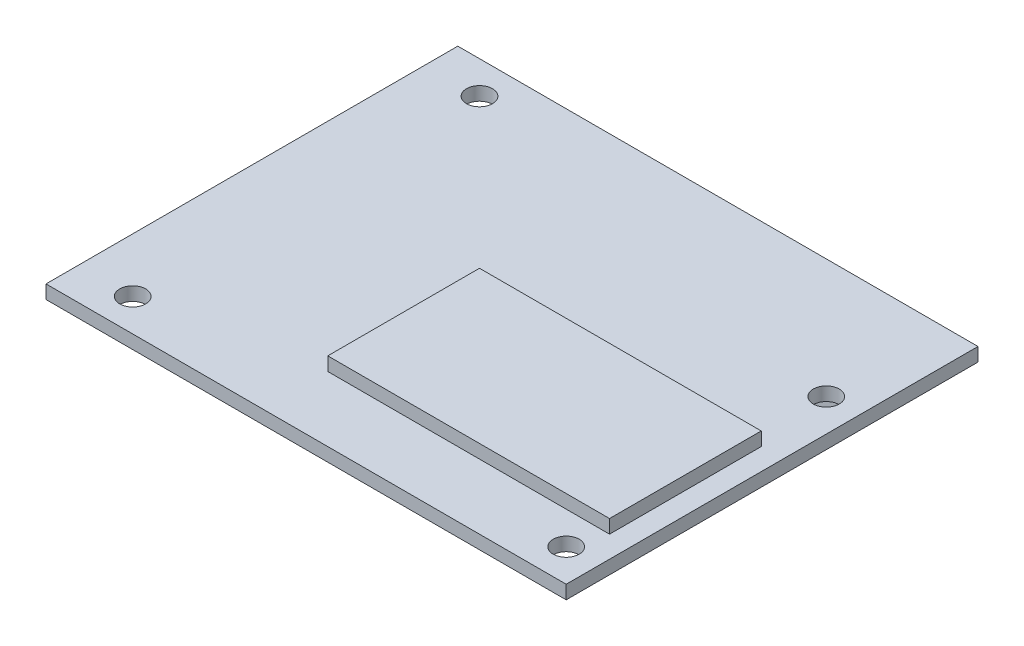
from build123d import *

# Parameters (mm, degrees)
SKETCH1_W           = 60.96
SKETCH1_H           = 48.26
BOSS_EXTRUDE1_DEPTH = 1.5875
SKETCH2_W           = 33.02
SKETCH2_H           = 17.78
BOSS_EXTRUDE2_DEPTH = 1.5875
SKETCH3_R           = 1.524
CUT_EXTRUDE1_DEPTH  = 2.5875
SKETCH4_W           = 12.7
SKETCH4_H           = 2.54
BOSS_EXTRUDE3_DEPTH = 10.16


with BuildPart() as part:
    # Sketch1 → Boss-Extrude1 (new body)
    with BuildSketch(Plane(origin=(0, 0, 0), x_dir=(1, 0, 0), z_dir=(0, 1, 0))):
        with Locations((1.00761446, -5.459482072)):
            Rectangle(SKETCH1_W, SKETCH1_H)
    extrude(amount=BOSS_EXTRUDE1_DEPTH)

    # Sketch2 → Boss-Extrude2 (add)
    with BuildSketch(Plane(origin=(0, 1.5875, 0), x_dir=(1, 0, 0), z_dir=(0, 1, 0))):
        with Locations((12.43761446, -13.079482072)):
            Rectangle(SKETCH2_W, SKETCH2_H)
    extrude(amount=BOSS_EXTRUDE2_DEPTH)

    # Sketch3 → Cut-Extrude1 (cut, through all)
    with BuildSketch(Plane(origin=(0, 1.5875, 0), x_dir=(1, 0, 0), z_dir=(0, 1, 0))):
        with Locations((-23.12238554, 14.860517928)):
            Circle(SKETCH3_R)
        with Locations((27.67761446, 4.700517928)):
            Circle(SKETCH3_R)
        with Locations((-23.12238554, -25.779482072)):
            Circle(SKETCH3_R)
        with Locations((27.67761446, -25.779482072)):
            Circle(SKETCH3_R)
    extrude(amount=-CUT_EXTRUDE1_DEPTH, mode=Mode.SUBTRACT)

    # Sketch4 → Boss-Extrude3 (add)
    with BuildSketch(Plane(origin=(0, 0, 0), x_dir=(-1, 0, 0), z_dir=(0, -1, 0))):
        with Locations((-14.97761446, 14.860517928)):
            Rectangle(SKETCH4_W, SKETCH4_H)
    extrude(amount=BOSS_EXTRUDE3_DEPTH)


solid = part.part
